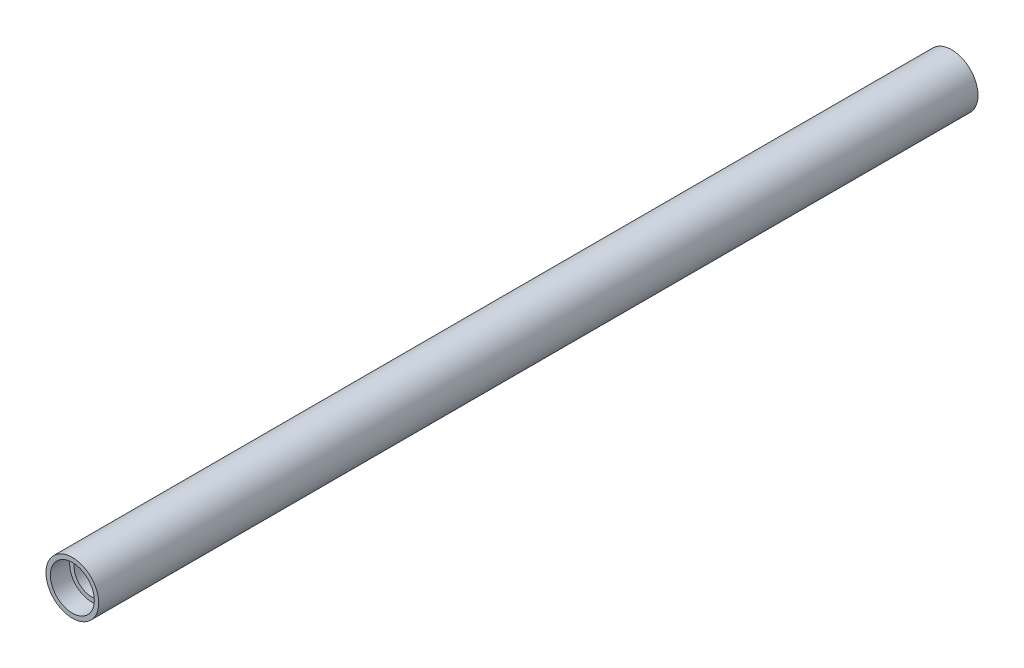
from build123d import *

# Parameters (mm, degrees)
SKETCH1_R           = 7.5
SKETCH1_R_2         = 5
BOSS_EXTRUDE1_DEPTH = 125
SKETCH2_R           = 6.25
CUT_EXTRUDE1_DEPTH  = 5.5


with BuildPart() as part:
    # Sketch1 → Boss-Extrude1 (new body, symmetric)
    with BuildSketch(Plane.XY):
        Circle(SKETCH1_R)
        Circle(SKETCH1_R_2, mode=Mode.SUBTRACT)
    extrude(amount=BOSS_EXTRUDE1_DEPTH, both=True)

    # Sketch2 → Cut-Extrude1 (cut)
    with BuildSketch(Plane.XY.offset(125)):
        Circle(SKETCH2_R)
    cut_extrude1 = extrude(amount=-CUT_EXTRUDE1_DEPTH, mode=Mode.SUBTRACT)

    # Mirror1: Cut-Extrude1 across plane
    add(cut_extrude1.mirror(Plane.XY), mode=Mode.SUBTRACT)


solid = part.part
